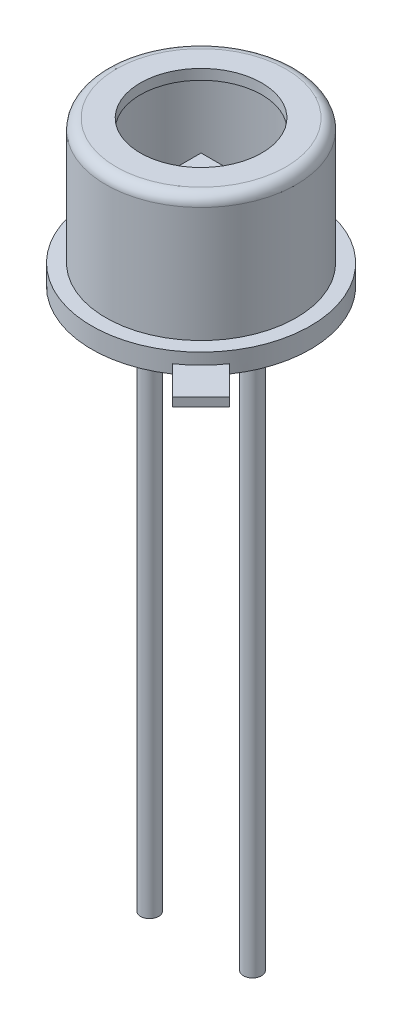
from build123d import *

# Parameters (mm, degrees)
SKETCH2_R           = 2.7
BOSS_EXTRUDE1_DEPTH = 0.246
BOSS_EXTRUDE2_START = -2.3
SKETCH3_W           = 1.1
SKETCH3_H           = 1.1
BOSS_EXTRUDE2_DEPTH = 0.05
BOSS_EXTRUDE7_DEPTH = 0.22
SKETCH5_R           = 0.225
BOSS_EXTRUDE8_DEPTH = 14


with BuildPart() as part:
    # Sketch1 → Revolve-Thin2 (revolve)
    with BuildSketch(Plane.XY, mode=Mode.PRIVATE) as revolve_thin2_sk:
        with BuildLine():
            Line((2.7, 0), (2.7, 0.5))
            Line((2.7, 0.5), (2.35, 0.5))
            Line((2.35, 0.5), (2.35, 3.346))
            ThreePointArc((2.35, 3.346), (2.275605122, 3.525605122), (2.096, 3.6))
            Line((2.096, 3.6), (1.5, 3.6))
            Line((1.5, 3.6), (1.5, 3.346))
            Line((1.5, 3.346), (2.096, 3.346))
            Line((2.096, 3.346), (2.096, 0.246))
            Line((2.096, 0.246), (2.446, 0.246))
            Line((2.446, 0.246), (2.446, 0))
            Line((2.446, 0), (2.7, 0))
        make_face()
    revolve(revolve_thin2_sk.sketch.rotate(Axis((0, 0, 0), (0, 1, 0)), 90), axis=Axis((0, 0, 0), (0, 1, 0)))  # turned: the seam where the file's is

    # Sketch2 → Boss-Extrude1 (add)
    with BuildSketch(Plane.XZ):
        with Locations(Location((0, 0, 0), (0, 0, 270))):  # turned: the seam where the file's is
            Circle(SKETCH2_R)
    extrude(amount=-BOSS_EXTRUDE1_DEPTH)

    # Sketch10 → Boss-Extrude7 (add)
    with BuildSketch(Plane.XZ):
        Polygon((1.522612913, 2.229719695), (2.229719695, 1.522612913), (2.936826476, 2.229719695), (2.229719695, 2.936826476), align=None)
    extrude(amount=-BOSS_EXTRUDE7_DEPTH)

    # Sketch5 → Boss-Extrude8 (add)
    with BuildSketch(Plane.XZ):
        with Locations(Location((1.27, 0, 0), (0, 0, 270))):  # turned: the seam where the file's is
            Circle(SKETCH5_R)
        with Locations(Location((-1.27, 0, 0), (0, 0, 90))):  # turned: the seam where the file's is
            Circle(SKETCH5_R)
    extrude(amount=BOSS_EXTRUDE8_DEPTH)


with BuildPart() as body_2:
    # Sketch3 → Boss-Extrude2 (new body)
    with BuildSketch(Plane.XZ.offset(BOSS_EXTRUDE2_START)):
        Rectangle(SKETCH3_W, SKETCH3_H)
    extrude(amount=BOSS_EXTRUDE2_DEPTH)


solid = Compound([part.part, body_2.part])
